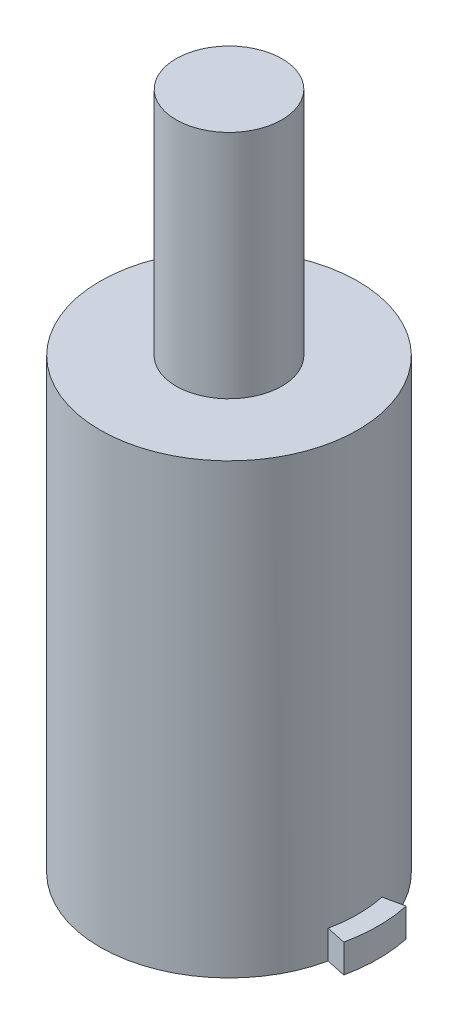
from build123d import *

# Parameters (mm, degrees)
SKETCH1_R           = 4.75
BOSS_EXTRUDE1_DEPTH = 16.5
SKETCH2_R           = 1.95
BOSS_EXTRUDE2_DEPTH = 8.5
BOSS_EXTRUDE3_DEPTH = 1.05


with BuildPart() as part:
    # Sketch1 → Boss-Extrude1 (new body)
    with BuildSketch(Plane(origin=(0, 0, 0), x_dir=(1, 0, 0), z_dir=(0, 1, 0))):
        Circle(SKETCH1_R)
    extrude(amount=BOSS_EXTRUDE1_DEPTH)

    # Sketch2 → Boss-Extrude2 (add)
    with BuildSketch(Plane(origin=(0, 16.5, 0), x_dir=(1, 0, 0), z_dir=(0, 1, 0))):
        Circle(SKETCH2_R)
    extrude(amount=BOSS_EXTRUDE2_DEPTH)

    # Sketch3 → Boss-Extrude3 (add)
    with BuildSketch(Plane.XZ):
        with BuildLine():
            Line((-5.378429139, 1.15), (-4.645006983, 0.993181818))
            ThreePointArc((-4.645006983, 0.993181818), (-4.75, 0), (-4.645006983, -0.993181818))
            Line((-4.645006983, -0.993181818), (-5.378429139, -1.15))
            ThreePointArc((-5.378429139, -1.15), (-5.5, 0), (-5.378429139, 1.15))
        make_face()
        with BuildLine():
            Line((4.645006983, -0.993181818), (5.378429139, -1.15))
            ThreePointArc((5.378429139, -1.15), (5.5, 0), (5.378429139, 1.15))
            Line((5.378429139, 1.15), (4.645006983, 0.993181818))
            ThreePointArc((4.645006983, 0.993181818), (4.75, 0), (4.645006983, -0.993181818))
        make_face()
    extrude(amount=-BOSS_EXTRUDE3_DEPTH)


solid = part.part
